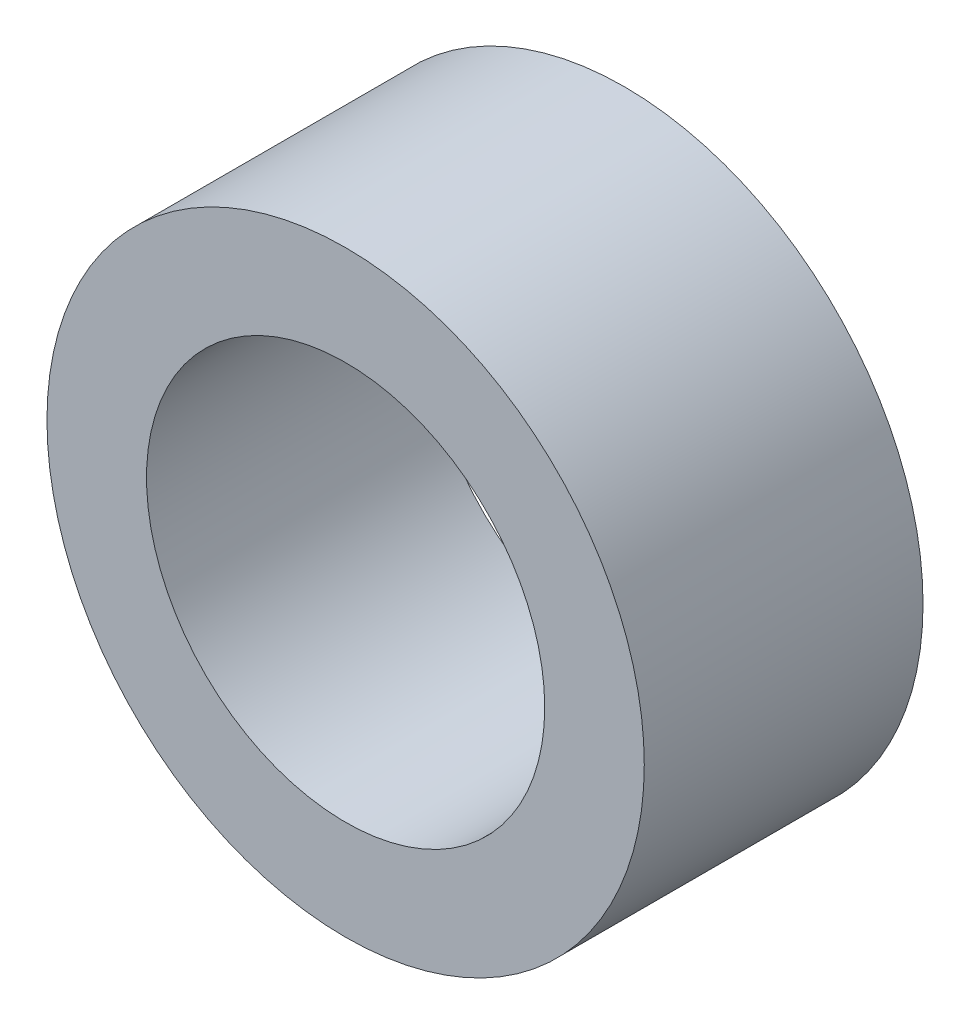
from build123d import *

# Parameters (mm, degrees)
SKETCH1_R           = 30
SKETCH1_R_2         = 20
BOSS_EXTRUDE1_DEPTH = 28


with BuildPart() as part:
    # Sketch1 → Boss-Extrude1 (new body)
    with BuildSketch(Plane.XY):
        Circle(SKETCH1_R)
        Circle(SKETCH1_R_2, mode=Mode.SUBTRACT)
    extrude(amount=BOSS_EXTRUDE1_DEPTH)


solid = part.part
